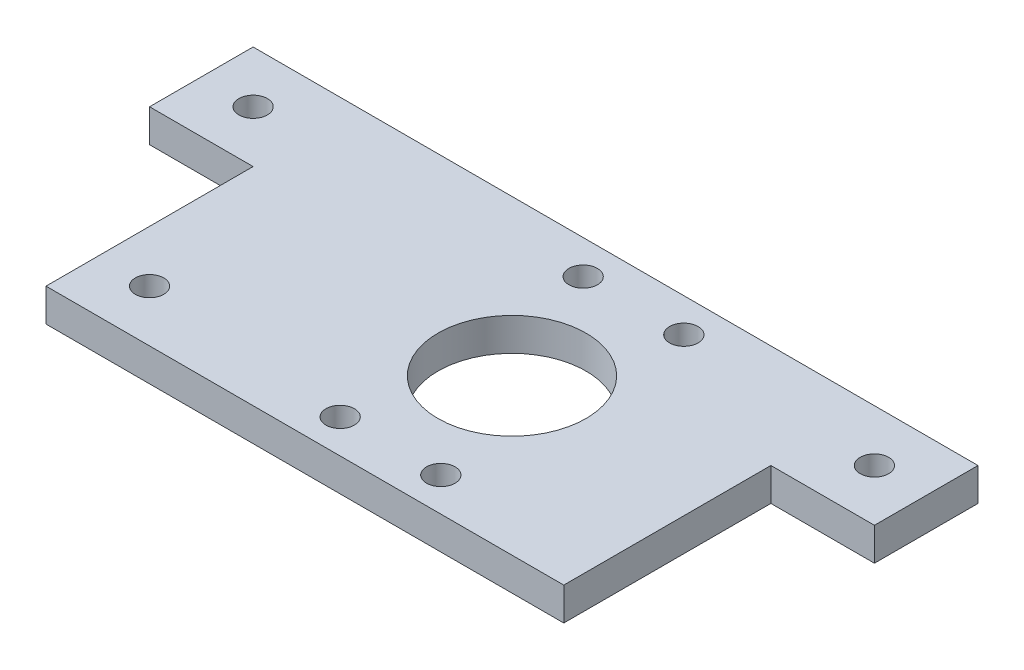
from build123d import *

# Parameters (mm, degrees)
SKETCH1_W           = 140
SKETCH1_H           = 60
BOSS_EXTRUDE1_DEPTH = 6.35
SKETCH3_R           = 14.295
SKETCH3_R_2         = 2.75
CUT_EXTRUDE2_DEPTH  = 7.35
CUT_EXTRUDE3_REACH  = 8.35
SKETCH4_R           = 2.75
SKETCH4_W           = 20
SKETCH4_H           = 40


with BuildPart() as part:
    # Sketch1 → Boss-Extrude1 (new body)
    with BuildSketch(Plane(origin=(0, 0, 0), x_dir=(1, 0, 0), z_dir=(0, 1, 0))):
        with Locations((11.204600864, 33.763107794)):
            Rectangle(SKETCH1_W, SKETCH1_H)
    extrude(amount=BOSS_EXTRUDE1_DEPTH)

    # Sketch3 → Cut-Extrude2 (cut, through all)
    with BuildSketch(Plane(origin=(0, 6.35, 0), x_dir=(1, 0, 0), z_dir=(0, 1, 0))):
        with Locations((21.204600864, 33.763107794)):
            Circle(SKETCH3_R)
        with Locations((30.924600864, 10.296501734)):
            Circle(SKETCH3_R_2)
        with Locations((11.484600864, 10.296501734)):
            Circle(SKETCH3_R_2)
        with Locations((11.484600864, 57.229713855)):
            Circle(SKETCH3_R_2)
        with Locations((30.924600864, 57.229713855)):
            Circle(SKETCH3_R_2)
    extrude(amount=-CUT_EXTRUDE2_DEPTH, mode=Mode.SUBTRACT)

    # Sketch4 → Cut-Extrude3 (cut, up to next)
    with BuildSketch(Plane(origin=(0, 6.35, 0), x_dir=(1, 0, 0), z_dir=(0, 1, 0)), mode=Mode.PRIVATE) as cut_extrude3_sk1:
        with Locations((71.204600864, 53.763107794)):
            Circle(SKETCH4_R)
    cut_extrude3_tool1 = extrude(cut_extrude3_sk1.sketch, amount=-CUT_EXTRUDE3_REACH, mode=Mode.PRIVATE) & part.part
    add(cut_extrude3_tool1.solids().sort_by_distance((71.204601, 6.35, -53.763108))[0], mode=Mode.SUBTRACT)
    # Sketch4 → Cut-Extrude3 (cut, up to next)
    with BuildSketch(Plane(origin=(0, 6.35, 0), x_dir=(1, 0, 0), z_dir=(0, 1, 0)), mode=Mode.PRIVATE) as cut_extrude3_sk2:
        with Locations((-48.795399136, 53.763107794)):
            Circle(SKETCH4_R)
    cut_extrude3_tool2 = extrude(cut_extrude3_sk2.sketch, amount=-CUT_EXTRUDE3_REACH, mode=Mode.PRIVATE) & part.part
    add(cut_extrude3_tool2.solids().sort_by_distance((-48.795399, 6.35, -53.763108))[0], mode=Mode.SUBTRACT)
    # Sketch4 → Cut-Extrude3 (cut, up to next)
    with BuildSketch(Plane(origin=(0, 6.35, 0), x_dir=(1, 0, 0), z_dir=(0, 1, 0)), mode=Mode.PRIVATE) as cut_extrude3_sk3:
        with Locations((-28.795399136, 13.763107794)):
            Circle(SKETCH4_R)
    cut_extrude3_tool3 = extrude(cut_extrude3_sk3.sketch, amount=-CUT_EXTRUDE3_REACH, mode=Mode.PRIVATE) & part.part
    add(cut_extrude3_tool3.solids().sort_by_distance((-28.795399, 6.35, -13.763108))[0], mode=Mode.SUBTRACT)
    # Sketch4 → Cut-Extrude3 (cut, up to next)
    with BuildSketch(Plane(origin=(0, 6.35, 0), x_dir=(1, 0, 0), z_dir=(0, 1, 0)), mode=Mode.PRIVATE) as cut_extrude3_sk4:
        with Locations((71.204600864, 23.763107794)):
            Rectangle(SKETCH4_W, SKETCH4_H)
    cut_extrude3_tool4 = extrude(cut_extrude3_sk4.sketch, amount=-CUT_EXTRUDE3_REACH, mode=Mode.PRIVATE) & part.part
    add(cut_extrude3_tool4.solids().sort_by_distance((71.204601, 6.35, -23.763108))[0], mode=Mode.SUBTRACT)
    # Sketch4 → Cut-Extrude3 (cut, up to next)
    with BuildSketch(Plane(origin=(0, 6.35, 0), x_dir=(1, 0, 0), z_dir=(0, 1, 0)), mode=Mode.PRIVATE) as cut_extrude3_sk5:
        with Locations((-48.795399136, 23.763107794)):
            Rectangle(SKETCH4_W, SKETCH4_H)
    cut_extrude3_tool5 = extrude(cut_extrude3_sk5.sketch, amount=-CUT_EXTRUDE3_REACH, mode=Mode.PRIVATE) & part.part
    add(cut_extrude3_tool5.solids().sort_by_distance((-48.795399, 6.35, -23.763108))[0], mode=Mode.SUBTRACT)


solid = part.part
